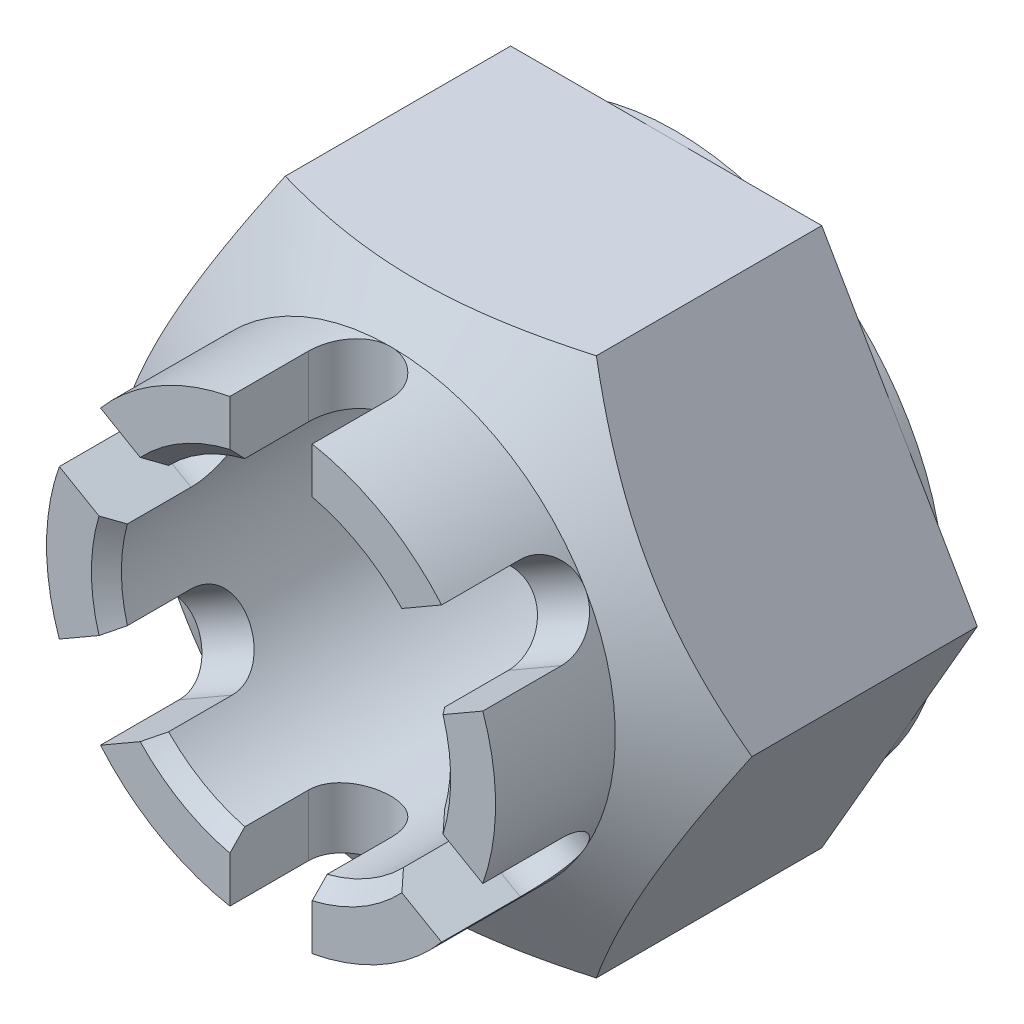
from build123d import *

# Parameters (mm, degrees)
BOSS_EXTRUDE1_DEPTH     = 19
SKETCH2_R               = 15
BOSS_EXTRUDE2_DEPTH     = 8
SKETCH4_R               = 28
SKETCH4_R_2             = 18
CUT_EXTRUDE_THIN1_DEPTH = 0.6
CUT_EXTRUDE1_REACH      = 40.536
SKETCH5_R               = 11
CUT_EXTRUDE2_REACH      = 40.536
CIRPATTERN1_COUNT       = 6
CHAMFER1_SIZE           = 1


with BuildPart() as part:
    # Sketch1 → Boss-Extrude1 (new body)
    with BuildSketch(Plane.XY):
        Polygon((20.784609691, 0), (10.392304845, 18), (-10.392304845, 18), (-20.784609691, 0), (-10.392304845, -18), (10.392304845, -18), align=None)
    extrude(amount=BOSS_EXTRUDE1_DEPTH)

    # Sketch2 → Boss-Extrude2 (add)
    with BuildSketch(Plane.XY.offset(19)):
        Circle(SKETCH2_R)
    extrude(amount=BOSS_EXTRUDE2_DEPTH)

    # Sketch3 → Cut-Revolve1 (revolve, cut)
    with BuildSketch(Plane(origin=(0, 0, 0), x_dir=(0, 0, -1), z_dir=(1, 0, 0))):
        Polygon((-19, 15), (-19, 25.977792564), (-12.661968508, 25.977792564), align=None)
    revolve(axis=Axis((0, 0, -102.328960849), (0, 0, 1)), mode=Mode.SUBTRACT)

    # Sketch4 → Cut-Extrude-Thin1 (cut)
    with BuildSketch(Plane(origin=(0, 0, 0), x_dir=(-1, 0, 0), z_dir=(0, 0, -1))):
        Circle(SKETCH4_R)
        Circle(SKETCH4_R_2, mode=Mode.SUBTRACT)
    extrude(amount=-CUT_EXTRUDE_THIN1_DEPTH, mode=Mode.SUBTRACT)

    # Sketch5 → Cut-Extrude1 (cut, up to next)
    with BuildSketch(Plane.XY.offset(27), mode=Mode.PRIVATE) as cut_extrude1_sk1:
        Circle(SKETCH5_R)
    cut_extrude1_tool1 = extrude(cut_extrude1_sk1.sketch, amount=-CUT_EXTRUDE1_REACH, mode=Mode.PRIVATE) & part.part
    add(cut_extrude1_tool1.solids().sort_by_distance((0, 0, 27))[0], mode=Mode.SUBTRACT)

    # Sketch6 → Cut-Extrude2 (cut, up to next)
    with BuildSketch(Plane(origin=(0, 0, 0), x_dir=(1, 0, 0), z_dir=(0, 1, 0)), mode=Mode.PRIVATE) as cut_extrude2_sk1:
        with BuildLine():
            Line((-2.75, -21.75), (-2.75, -27))
            Line((-2.75, -27), (2.75, -27))
            Line((2.75, -27), (2.75, -21.75))
            ThreePointArc((2.75, -21.75), (0, -19), (-2.75, -21.75))
        make_face()
    cut_extrude2_tool1 = extrude(cut_extrude2_sk1.sketch, amount=-CUT_EXTRUDE2_REACH, mode=Mode.PRIVATE) & part.part
    cut_extrude2 = cut_extrude2_tool1.solids().sort_by_distance((0, 0, 23.269656))[0]
    add(cut_extrude2, mode=Mode.SUBTRACT)

    # CirPattern1: Cut-Extrude2 ×6 about axis
    cirpattern1_axis = Axis((0, 0, -0.001), (0, 0, 1))
    for i in range(1, CIRPATTERN1_COUNT):
        add(cut_extrude2.rotate(cirpattern1_axis, i * 360 / CIRPATTERN1_COUNT), mode=Mode.SUBTRACT)

    # Chamfer1
    chamfer1_edges = [part.edges().sort_by_distance(p)[0] for p in [
        (-5.5, -9.526279442, 27),
        (-11, 0, 27),
        (-5.5, 9.526279442, 27),
        (5.5, 9.526279442, 27),
        (10.899233562, -1.485499162, 27),
        (5.5, -9.526279442, 27),
        (-11, 0, 0),
    ]]
    chamfer(chamfer1_edges, length=CHAMFER1_SIZE)


solid = part.part
